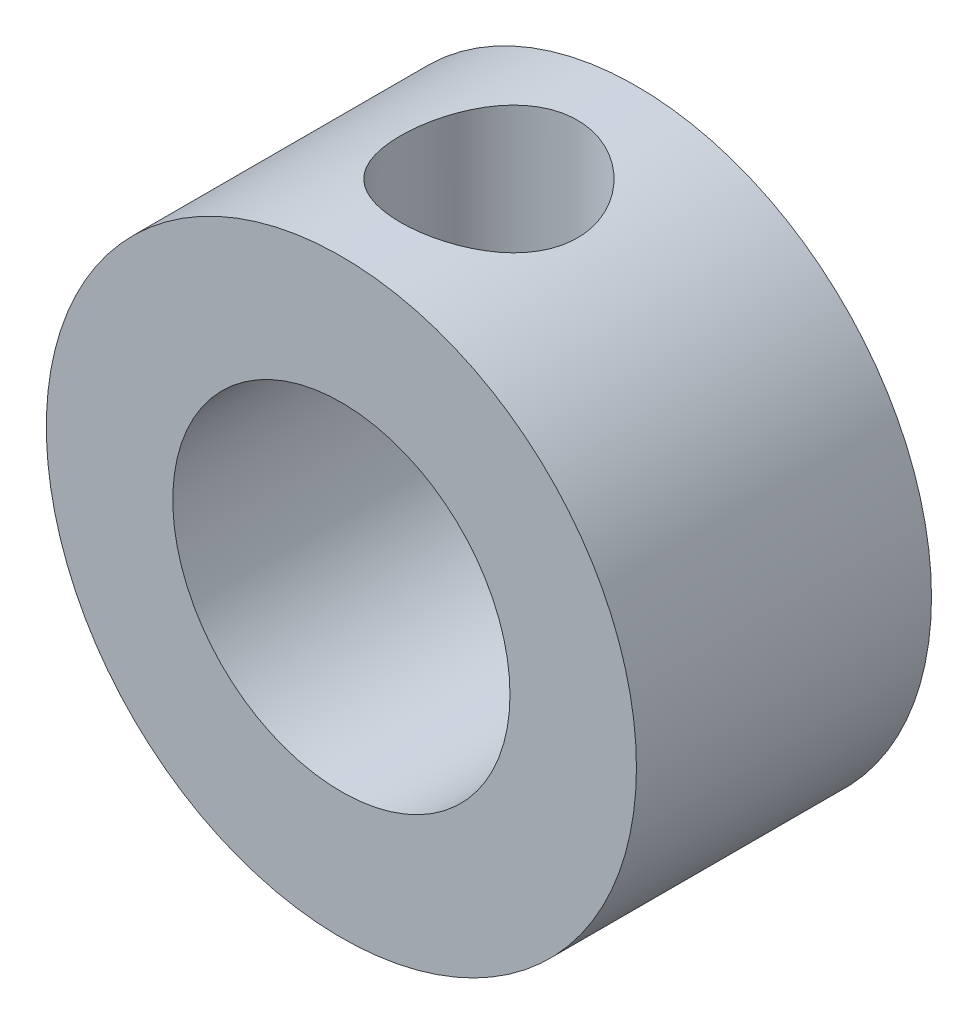
from build123d import *

# Parameters (mm, degrees)
SKETCH1_R                  = 7
SKETCH1_R_2                = 4
BOSS_EXTRUDE1_DEPTH        = 7
M5X0_8_TAPPED_HOLE1_REACH  = 19.146
M5X0_8_TAPPED_HOLE1_BORE_R = 2.1


with BuildPart() as part:
    # Sketch1 → Boss-Extrude1 (new body)
    with BuildSketch(Plane.XY):
        Circle(SKETCH1_R)
        Circle(SKETCH1_R_2, mode=Mode.SUBTRACT)
    extrude(amount=BOSS_EXTRUDE1_DEPTH)

    # M5x0.8 Tapped Hole1 bore → M5x0.8 Tapped Hole1 (cut, up to next)
    with BuildSketch(Plane(origin=(0, 7, 0), x_dir=(1, 0, 0), z_dir=(0, 1, 0)), mode=Mode.PRIVATE) as m5x0_8_tapped_hole1_sk1:
        with Locations((0, -3.5)):
            Circle(M5X0_8_TAPPED_HOLE1_BORE_R)
    m5x0_8_tapped_hole1_tool1 = extrude(m5x0_8_tapped_hole1_sk1.sketch, amount=-M5X0_8_TAPPED_HOLE1_REACH, mode=Mode.PRIVATE) & part.part
    add(m5x0_8_tapped_hole1_tool1.solids().sort_by_distance((0, 7, 3.5))[0], mode=Mode.SUBTRACT)


solid = part.part
